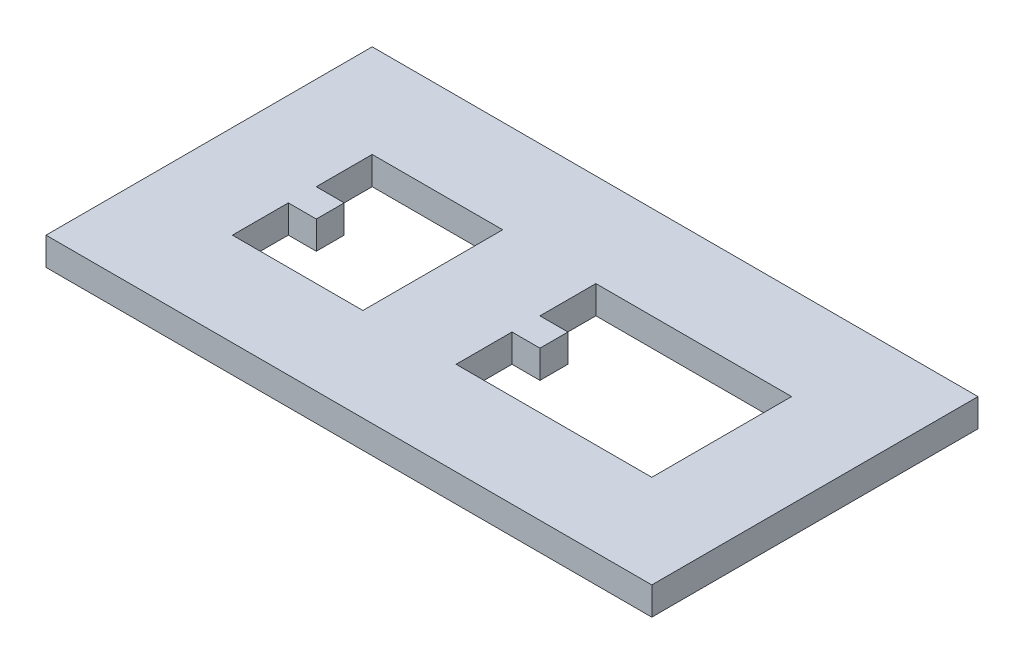
from build123d import *

# Parameters (mm, degrees)
SKETCH1_W           = 3
SKETCH1_H           = 3
SKETCH1_W_2         = 14
SKETCH1_H_2         = 10
BOSS_EXTRUDE1_DEPTH = 3


with BuildPart() as part:
    # Sketch1 → Boss-Extrude1 (new body)
    with BuildSketch(Plane(origin=(0, 0, 0), x_dir=(1, 0, 0), z_dir=(0, 1, 0))):
        Polygon((-2.229716691, 32.311583722), (-23.229716691, 32.311583722), (-23.229716691, 22.311583722), (7.770283309, 22.311583722), (7.770283309, 57.311583722), (-23.229716691, 57.311583722), (-23.229716691, 47.311583722), (-2.229716691, 47.311583722), align=None)
        with Locations((-21.729716691, 39.811583722)):
            Rectangle(SKETCH1_W, SKETCH1_H)
        Polygon((-23.229716691, 32.311583722), (-23.229716691, 34.311583722), (-23.229716691, 38.311583722), (-33.229716691, 38.311583722), (-33.229716691, 32.311583722), (-33.229716691, 22.311583722), (-23.229716691, 22.311583722), align=None)
        Polygon((-33.229716691, 38.311583722), (-23.229716691, 38.311583722), (-23.229716691, 41.311583722), (-23.229716691, 45.311583722), (-23.229716691, 47.311583722), (-23.229716691, 57.311583722), (-33.229716691, 57.311583722), (-33.229716691, 47.311583722), align=None)
        with Locations((-40.229716691, 52.311583722)):
            Rectangle(SKETCH1_W_2, SKETCH1_H_2)
        with Locations((-40.229716691, 27.311583722)):
            Rectangle(SKETCH1_W_2, SKETCH1_H_2)
        Polygon((-47.229716691, 22.311583722), (-47.229716691, 32.311583722), (-47.229716691, 34.311583722), (-47.229716691, 38.311583722), (-57.229716691, 38.311583722), (-57.229716691, 22.311583722), align=None)
        Polygon((-47.229716691, 45.311583722), (-47.229716691, 47.311583722), (-47.229716691, 57.311583722), (-57.229716691, 57.311583722), (-57.229716691, 38.311583722), (-47.229716691, 38.311583722), (-47.229716691, 41.311583722), align=None)
        with Locations((-45.729716691, 39.811583722)):
            Rectangle(SKETCH1_W, SKETCH1_H)
    extrude(amount=BOSS_EXTRUDE1_DEPTH)


solid = part.part
